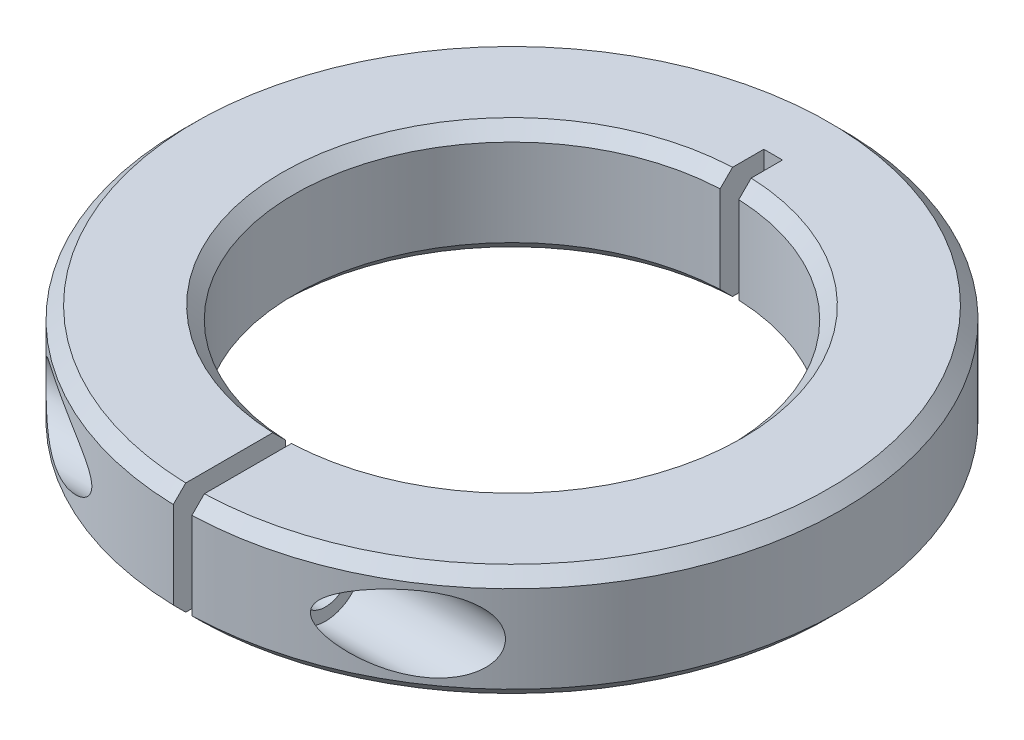
from build123d import *

# Parameters (mm, degrees)
BOSS_EXTRUDE1_DEPTH     = 9
CHAMFER1_SIZE           = 1
CUT_EXTRUDE2_DEPTH      = 39.542184681
CUT_EXTRUDE2_DEPTH_BACK = 39.542184681
SKETCH2_R               = 3
SKETCH2_3_R             = 3
SKETCH2_3_R_2           = 2
BOSS_EXTRUDE2_DEPTH     = 7
CUT_EXTRUDE3_DEPTH      = 39.542184819
CUT_EXTRUDE3_DEPTH_BACK = 39.542184819
SKETCH3_W               = 1.5
SKETCH3_H               = 7.004177156


with BuildPart() as part:
    # Sketch1 → Boss-Extrude1 (new body)
    with BuildSketch(Plane(origin=(0, 0, 0), x_dir=(1, 0, 0), z_dir=(0, 1, 0))):
        with BuildLine():
            Line((-0.75, 21), (0.75, 21))
            Line((0.75, 21), (0.75, 17.483921185))
            ThreePointArc((0.75, 17.483921185), (17.5, 0), (0.75, -17.483921185))
            Line((0.75, -17.483921185), (0.75, -26.489384666))
            ThreePointArc((0.75, -26.489384666), (0, 26.5), (-0.75, -26.489384666))
            Line((-0.75, -26.489384666), (-0.75, -17.483921185))
            ThreePointArc((-0.75, -17.483921185), (-17.5, 0), (-0.75, 17.483921185))
            Line((-0.75, 17.483921185), (-0.75, 21))
        make_face()
    extrude(amount=BOSS_EXTRUDE1_DEPTH)

    # Chamfer1
    chamfer1_edges = [part.edges().sort_by_distance(p)[0] for p in [
        (-17.5, 0, 0),
        (17.5, 0, 0),
        (0, 0, -26.5),
        (0, 9, -26.5),
        (17.5, 9, 0),
        (-17.5, 9, 0),
    ]]
    chamfer(chamfer1_edges, length=CHAMFER1_SIZE)

    # Sketch2 → Cut-Extrude2 (cut, two sides: drawn at the far end of the back side and taken through both)
    with BuildSketch(Plane(origin=(0, 0, 0), x_dir=(0, 0, -1), z_dir=(1, 0, 0)).offset(-CUT_EXTRUDE2_DEPTH_BACK)):
        with Locations((-22, 4.5)):
            Circle(SKETCH2_R)
    extrude(amount=CUT_EXTRUDE2_DEPTH + CUT_EXTRUDE2_DEPTH_BACK, mode=Mode.SUBTRACT)

    # Sketch2_3 → Boss-Extrude2 (add, symmetric)
    with BuildSketch(Plane(origin=(0, 0, 0), x_dir=(0, 0, -1), z_dir=(1, 0, 0))):
        with Locations((-22, 4.5)):
            Circle(SKETCH2_3_R)
        with Locations((-22, 4.5)):
            Circle(SKETCH2_3_R_2, mode=Mode.SUBTRACT)
    extrude(amount=BOSS_EXTRUDE2_DEPTH, both=True)

    # Sketch3 → Cut-Extrude3 (cut, two sides: drawn at the far end of the back side and taken through both)
    with BuildSketch(Plane(origin=(0, 9, 0), x_dir=(1, 0, 0), z_dir=(0, 1, 0)).offset(-CUT_EXTRUDE3_DEPTH_BACK)):
        with Locations((0, -21.986879624)):
            Rectangle(SKETCH3_W, SKETCH3_H)
    extrude(amount=CUT_EXTRUDE3_DEPTH + CUT_EXTRUDE3_DEPTH_BACK, mode=Mode.SUBTRACT)


solid = part.part
